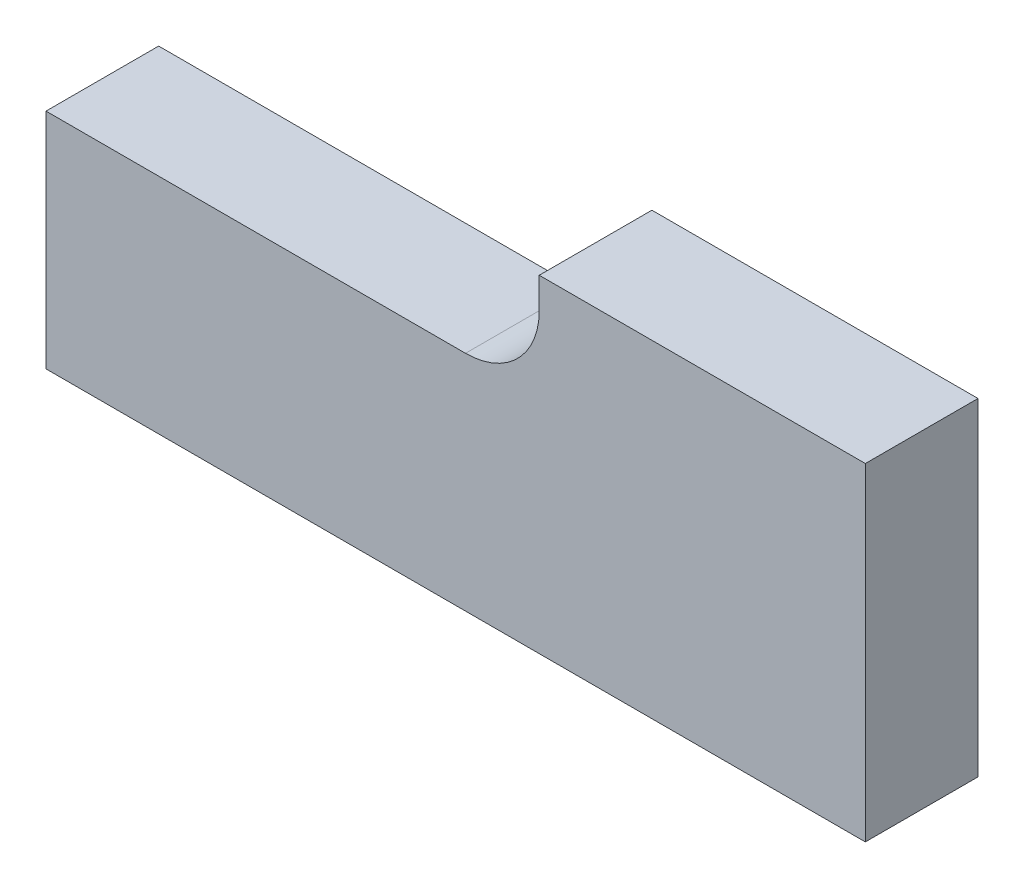
from build123d import *

# Parameters (mm, degrees)
BOSS_EXTRUDE2_DEPTH = 17.4625


with BuildPart() as part:
    # Sketch1 → Boss-Extrude2 (new body)
    with BuildSketch(Plane.XY):
        with BuildLine():
            Line((0, 0), (0, 34.6075))
            Line((0, 34.6075), (65.024, 34.6075))
            ThreePointArc((65.024, 34.6075), (73.106230509, 37.955269491), (76.454, 46.0375))
            Line((76.454, 46.0375), (76.454, 50.8))
            Line((76.454, 50.8), (127, 50.8))
            Line((127, 50.8), (127, 0))
            Line((127, 0), (0, 0))
        make_face()
    extrude(amount=BOSS_EXTRUDE2_DEPTH)


solid = part.part
